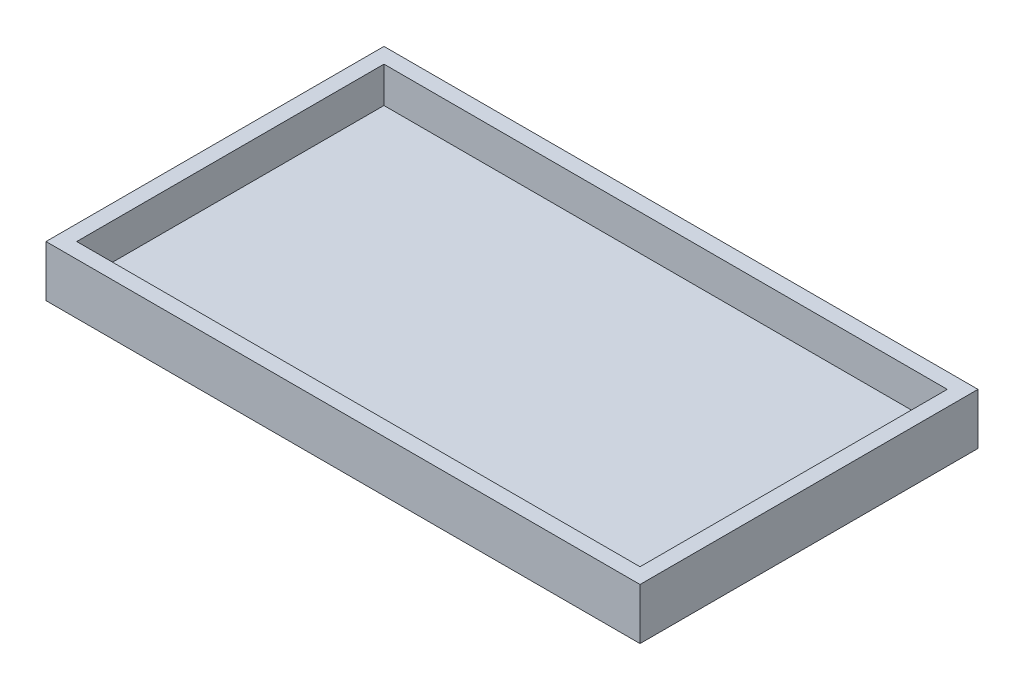
from build123d import *

# Parameters (mm, degrees)
SKETCH1_W           = 116
SKETCH1_H           = 66
BOSS_EXTRUDE1_DEPTH = 10
SHELL1_T            = -3


with BuildPart() as part:
    # Sketch1 → Boss-Extrude1 (new body)
    with BuildSketch(Plane(origin=(0, 0, 0), x_dir=(1, 0, 0), z_dir=(0, 1, 0))):
        with Locations((58, 33)):
            Rectangle(SKETCH1_W, SKETCH1_H)
    extrude(amount=BOSS_EXTRUDE1_DEPTH)

    # Shell1
    shell1_openings = [part.faces().sort_by_distance(p)[0] for p in [
        (58, 10, -33),
    ]]
    offset(amount=SHELL1_T, openings=shell1_openings, kind=Kind.INTERSECTION)


solid = part.part
